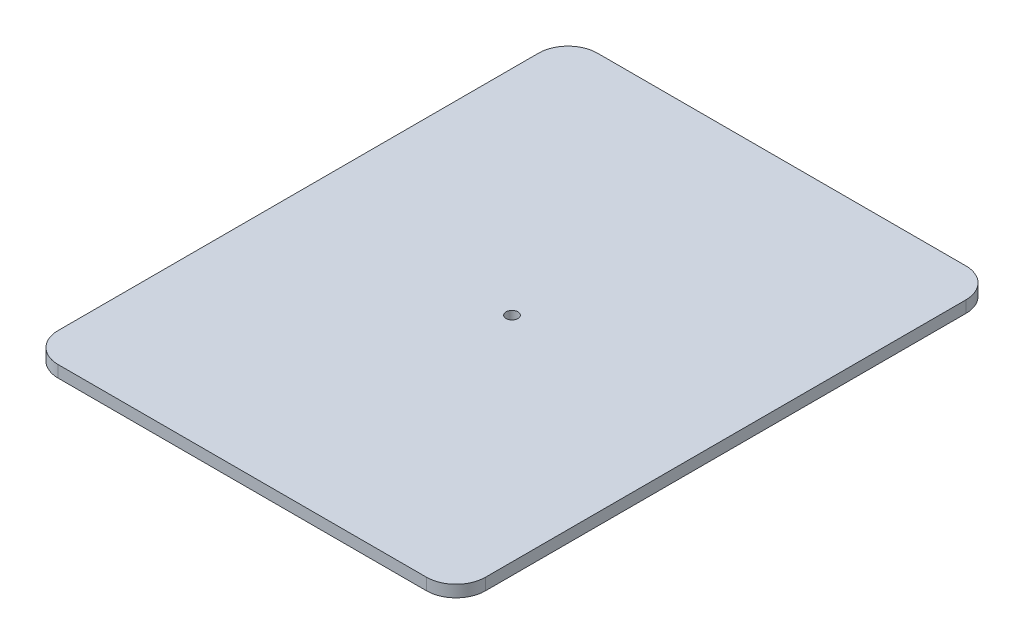
from build123d import *

# Parameters (mm, degrees)
SKETCH1_W           = 200
SKETCH1_H           = 200
SKETCH1_R           = 2
BOSS_EXTRUDE1_DEPTH = 4
FILLET1_R           = 10
SKETCH2_W           = 332.366301243
SKETCH2_H           = 358.749780036
CUT_EXTRUDE1_DEPTH  = 10


with BuildPart() as part:
    # Sketch1 → Boss-Extrude1 (new body)
    with BuildSketch(Plane(origin=(0, 0, 0), x_dir=(1, 0, 0), z_dir=(0, 1, 0))):
        Rectangle(SKETCH1_W, SKETCH1_H)
        Circle(SKETCH1_R, mode=Mode.SUBTRACT)
    extrude(amount=BOSS_EXTRUDE1_DEPTH)

    # Fillet1
    fillet1_edges = [part.edges().sort_by_distance(p)[0] for p in [
        (-100, 2, -100),
        (100, 2, -100),
        (100, 2, 100),
        (-100, 2, 100),
    ]]
    fillet(fillet1_edges, radius=FILLET1_R)

    # Sketch2 → Cut-Extrude1 (cut)
    with BuildSketch(Plane(origin=(0, 4, 0), x_dir=(1, 0, 0), z_dir=(0, 1, 0))):
        with Locations((1.781411531, 2.248264207)):
            Rectangle(SKETCH2_W, SKETCH2_H)
        with BuildLine():
            Line((-62.5, 91.5), (62.5, 91.5))
            ThreePointArc((62.5, 91.5), (69.571067812, 88.571067812), (72.5, 81.5))
            Line((72.5, 81.5), (72.5, -81.5))
            ThreePointArc((72.5, -81.5), (69.571067812, -88.571067812), (62.5, -91.5))
            Line((62.5, -91.5), (-62.5, -91.5))
            ThreePointArc((-62.5, -91.5), (-69.571067812, -88.571067812), (-72.5, -81.5))
            Line((-72.5, -81.5), (-72.5, 81.5))
            ThreePointArc((-72.5, 81.5), (-69.571067812, 88.571067812), (-62.5, 91.5))
        make_face(mode=Mode.SUBTRACT)
    extrude(amount=-CUT_EXTRUDE1_DEPTH, mode=Mode.SUBTRACT)


solid = part.part
